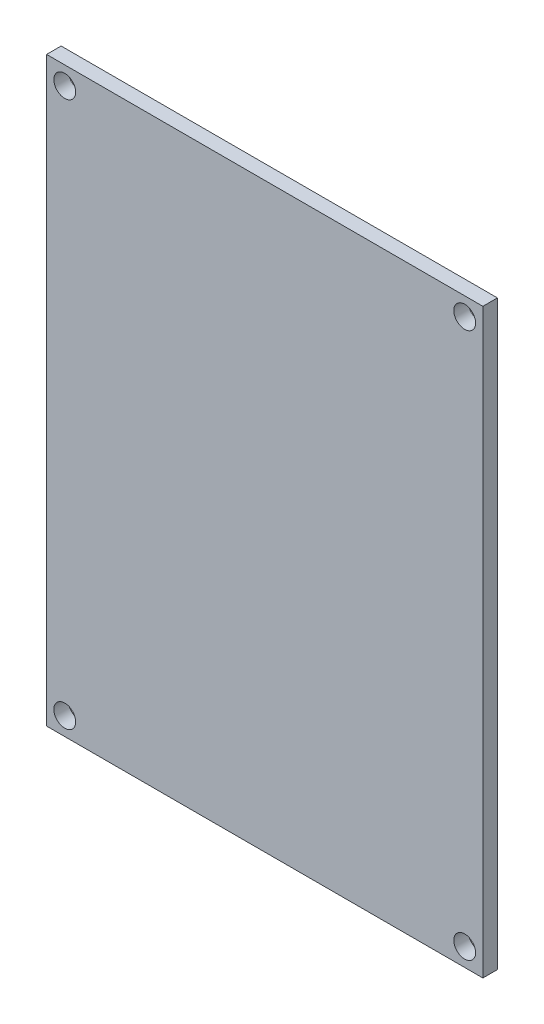
from build123d import *

# Parameters (mm, degrees)
CROQUIS1_W              = 60
CROQUIS1_H              = 80
SALIENTE_EXTRUIR1_DEPTH = 2
CORTAR_EXTRUIR1_REACH   = 4
CROQUIS2_R              = 1.5


with BuildPart() as part:
    # Croquis1 → Saliente-Extruir1 (new body)
    with BuildSketch(Plane.XY):
        Rectangle(CROQUIS1_W, CROQUIS1_H)
    extrude(amount=SALIENTE_EXTRUIR1_DEPTH)

    # Croquis2 → Cortar-Extruir1 (cut, up to next)
    with BuildSketch(Plane(origin=(0, 0, 0), x_dir=(-1, 0, 0), z_dir=(0, 0, -1)), mode=Mode.PRIVATE) as cortar_extruir1_sk1:
        with Locations((27.5, -37.5)):
            Circle(CROQUIS2_R)
    cortar_extruir1_tool1 = extrude(cortar_extruir1_sk1.sketch, amount=-CORTAR_EXTRUIR1_REACH, mode=Mode.PRIVATE) & part.part
    add(cortar_extruir1_tool1.solids().sort_by_distance((-27.5, -37.5, 0))[0], mode=Mode.SUBTRACT)
    # Croquis2 → Cortar-Extruir1 (cut, up to next)
    with BuildSketch(Plane(origin=(0, 0, 0), x_dir=(-1, 0, 0), z_dir=(0, 0, -1)), mode=Mode.PRIVATE) as cortar_extruir1_sk2:
        with Locations((-27.5, -37.5)):
            Circle(CROQUIS2_R)
    cortar_extruir1_tool2 = extrude(cortar_extruir1_sk2.sketch, amount=-CORTAR_EXTRUIR1_REACH, mode=Mode.PRIVATE) & part.part
    add(cortar_extruir1_tool2.solids().sort_by_distance((27.5, -37.5, 0))[0], mode=Mode.SUBTRACT)
    # Croquis2 → Cortar-Extruir1 (cut, up to next)
    with BuildSketch(Plane(origin=(0, 0, 0), x_dir=(-1, 0, 0), z_dir=(0, 0, -1)), mode=Mode.PRIVATE) as cortar_extruir1_sk3:
        with Locations((-27.5, 37.5)):
            Circle(CROQUIS2_R)
    cortar_extruir1_tool3 = extrude(cortar_extruir1_sk3.sketch, amount=-CORTAR_EXTRUIR1_REACH, mode=Mode.PRIVATE) & part.part
    add(cortar_extruir1_tool3.solids().sort_by_distance((27.5, 37.5, 0))[0], mode=Mode.SUBTRACT)
    # Croquis2 → Cortar-Extruir1 (cut, up to next)
    with BuildSketch(Plane(origin=(0, 0, 0), x_dir=(-1, 0, 0), z_dir=(0, 0, -1)), mode=Mode.PRIVATE) as cortar_extruir1_sk4:
        with Locations((27.5, 37.5)):
            Circle(CROQUIS2_R)
    cortar_extruir1_tool4 = extrude(cortar_extruir1_sk4.sketch, amount=-CORTAR_EXTRUIR1_REACH, mode=Mode.PRIVATE) & part.part
    add(cortar_extruir1_tool4.solids().sort_by_distance((-27.5, 37.5, 0))[0], mode=Mode.SUBTRACT)


solid = part.part
